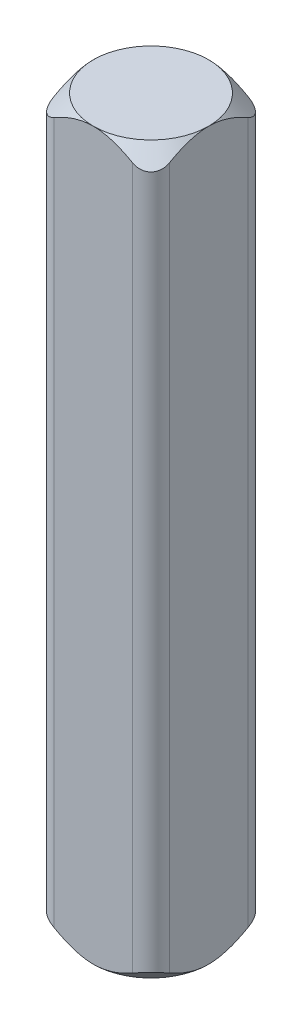
from build123d import *

# Parameters (mm, degrees)
SKETCH1_W           = 3.175
SKETCH1_H           = 3.175
BOSS_EXTRUDE1_DEPTH = 10
FILLET1_R           = 0.508


with BuildPart() as part:
    # Sketch1 → Boss-Extrude1 (new, symmetric)
    with BuildSketch(Plane(origin=(0, 0, 0), x_dir=(1, 0, 0), z_dir=(0, 1, 0))):
        Rectangle(SKETCH1_W, SKETCH1_H)
    extrude(amount=BOSS_EXTRUDE1_DEPTH, both=True)

    # Fillet1
    fillet1_edges = [part.edges().sort_by_distance(p)[0] for p in [
        (-1.5875, 0, -1.5875),
        (-1.5875, 0, 1.5875),
        (1.5875, 0, -1.5875),
        (1.5875, 0, 1.5875),
    ]]
    fillet(fillet1_edges, radius=FILLET1_R)

    # Sketch3 → Cut-Revolve3 (revolve, cut)
    with BuildSketch(Plane.XY):
        Polygon((1.5875, -10), (2.294606781, -9.292893219), (2.294606781, -11), (1.5875, -11), align=None)
    cut_revolve3 = revolve(axis=Axis((0, 0, 0), (0, -1, 0)), mode=Mode.SUBTRACT)

    # Mirror1: Cut-Revolve3 across plane
    add(cut_revolve3.mirror(Plane.ZX), mode=Mode.SUBTRACT)


solid = part.part
